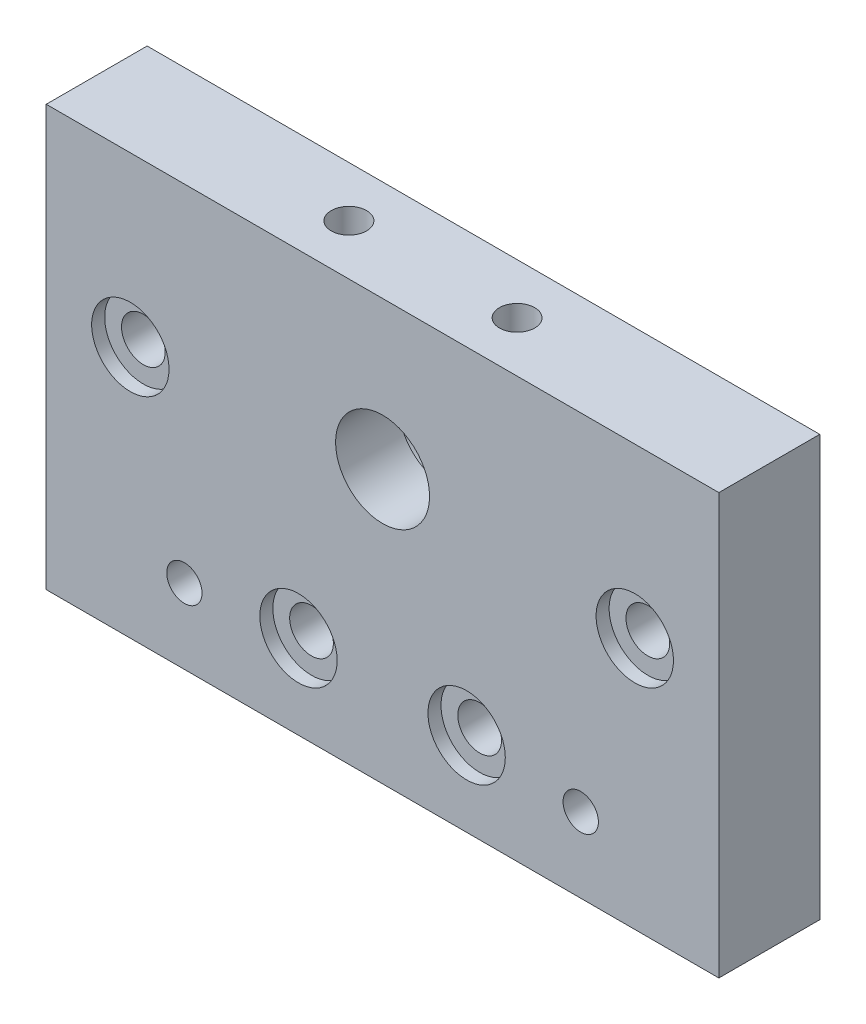
from build123d import *

# Parameters (mm, degrees)
SKETCH1_W                 = 80
SKETCH1_H                 = 50
SKETCH1_R                 = 5.588
SKETCH1_R_2               = 2.6
BOSS_EXTRUDE1_DEPTH       = 12
SKETCH2_R                 = 4.6
CUT_EXTRUDE1_DEPTH        = 1.55
M5X0_8_TAPPED_HOLE1_D     = 4.2
M5X0_8_TAPPED_HOLE2_D     = 4.2
M5X0_8_TAPPED_HOLE2_DEPTH = 14
M5X0_8_TAPPED_HOLE2_TIP   = 1.2618073
SKETCH7_R                 = 8.05
CUT_EXTRUDE2_DEPTH        = 4.5


with BuildPart() as part:
    # Sketch1 → Boss-Extrude1 (new body)
    with BuildSketch(Plane.XY):
        with Locations((40, 25)):
            Rectangle(SKETCH1_W, SKETCH1_H)
        with Locations((40, 32.4)):
            Circle(SKETCH1_R, mode=Mode.SUBTRACT)
        with Locations((30, 10)):
            Circle(SKETCH1_R_2, mode=Mode.SUBTRACT)
        with Locations((10, 30)):
            Circle(SKETCH1_R_2, mode=Mode.SUBTRACT)
        with Locations((50, 10)):
            Circle(SKETCH1_R_2, mode=Mode.SUBTRACT)
        with Locations((70, 30)):
            Circle(SKETCH1_R_2, mode=Mode.SUBTRACT)
    extrude(amount=BOSS_EXTRUDE1_DEPTH)

    # Sketch2 → Cut-Extrude1 (cut)
    with BuildSketch(Plane.XY.offset(12)):
        with Locations((10, 30)):
            Circle(SKETCH2_R)
        with Locations((30, 10)):
            Circle(SKETCH2_R)
        with Locations((50, 10)):
            Circle(SKETCH2_R)
        with Locations((70, 30)):
            Circle(SKETCH2_R)
    extrude(amount=-CUT_EXTRUDE1_DEPTH, mode=Mode.SUBTRACT)

    # M5x0.8 Tapped Hole1 (through all)
    with Locations(Plane.XY.offset(12)):
        with Locations((16.43, 8.9), (63.57, 8.9)):
            Hole(M5X0_8_TAPPED_HOLE1_D / 2)

    # M5x0.8 Tapped Hole2
    with Locations(Plane(origin=(0, 50, 0), x_dir=(1, 0, 0), z_dir=(0, 1, 0))):
        with Locations((30, -6), (50, -6)):
            Hole(M5X0_8_TAPPED_HOLE2_D / 2, depth=M5X0_8_TAPPED_HOLE2_DEPTH)
            with Locations((0, 0, -(M5X0_8_TAPPED_HOLE2_DEPTH + M5X0_8_TAPPED_HOLE2_TIP / 2))):  # 118° drill point
                Cone(0, M5X0_8_TAPPED_HOLE2_D / 2, M5X0_8_TAPPED_HOLE2_TIP, mode=Mode.SUBTRACT)

    # Sketch7 → Cut-Extrude2 (cut)
    with BuildSketch(Plane(origin=(0, 0, 0), x_dir=(-1, 0, 0), z_dir=(0, 0, -1))):
        with Locations((-40, 32.4)):
            Circle(SKETCH7_R)
    extrude(amount=-CUT_EXTRUDE2_DEPTH, mode=Mode.SUBTRACT)


solid = part.part
